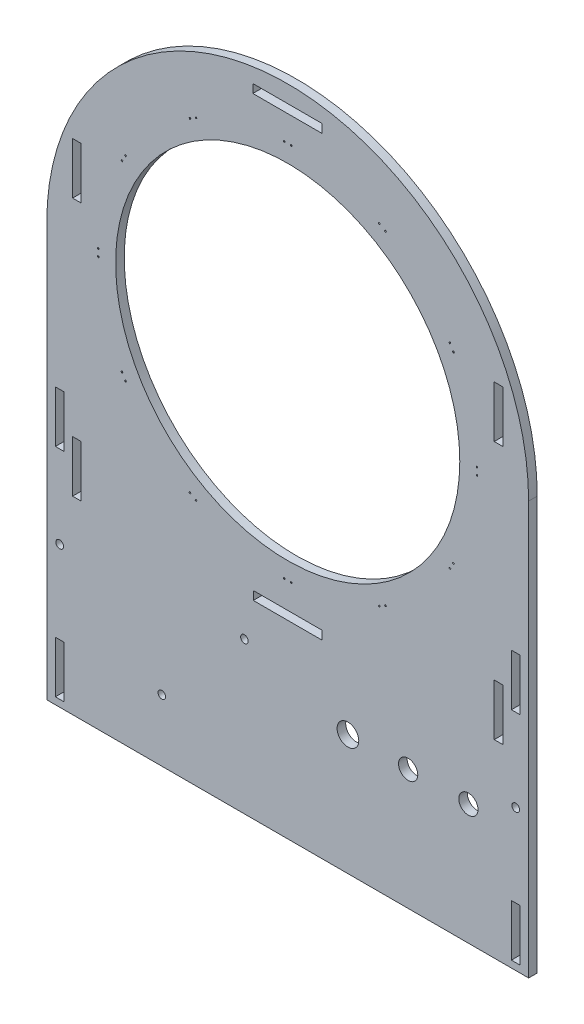
from build123d import *

# Parameters (mm, degrees)
SKETCH1_R           = 63.5
SKETCH1_R_2         = 1.4224
SKETCH1_R_3         = 4
SKETCH1_R_4         = 3.55
SKETCH1_R_5         = 1.397
SKETCH1_W           = 0.5334
SKETCH1_H           = 0.5334
SKETCH1_W_2         = 3.175
SKETCH1_H_2         = 19.05
SKETCH1_W_3         = 25.556343598
SKETCH1_H_3         = 3.175
SKETCH1_W_4         = 25.4
BOSS_EXTRUDE1_DEPTH = 3.175


with BuildPart() as part:
    # Sketch1 → Boss-Extrude1 (new body)
    with BuildSketch(Plane.XY):
        with BuildLine():
            Line((-88.9, 0), (-88.9, -152.4))
            Line((-88.9, -152.4), (88.9, -152.4))
            Line((88.9, -152.4), (88.9, 0))
            ThreePointArc((88.9, 0), (0, 88.9), (-88.9, 0))
        make_face()
        Circle(SKETCH1_R, mode=Mode.SUBTRACT)
        with Locations((-84.1375, -100.33)):
            Circle(SKETCH1_R_2, mode=Mode.SUBTRACT)
        with Locations((84.1375, -100.33)):
            Circle(SKETCH1_R_2, mode=Mode.SUBTRACT)
        with Locations((22.225, -107.95)):
            Circle(SKETCH1_R_3, mode=Mode.SUBTRACT)
        with Locations((44.45, -107.95)):
            Circle(SKETCH1_R_4, mode=Mode.SUBTRACT)
        with Locations((66.675, -107.95)):
            Circle(SKETCH1_R_4, mode=Mode.SUBTRACT)
        with Locations((-15.977581987, -96.52)):
            Circle(SKETCH1_R_5, mode=Mode.SUBTRACT)
        with Locations((-46.457581987, -129.54)):
            Circle(SKETCH1_R_5, mode=Mode.SUBTRACT)
        with Locations((-1.30175, 69.85)):
            Rectangle(SKETCH1_W, SKETCH1_H, mode=Mode.SUBTRACT)
        with Locations((1.30175, 69.85)):
            Rectangle(SKETCH1_W, SKETCH1_H, mode=Mode.SUBTRACT)
        Polygon((33.700032455, 61.50706843), (34.161970406, 61.24036843), (33.895270406, 60.778430479), (33.433332455, 61.045130479), align=None, mode=Mode.SUBTRACT)
        Polygon((35.954729594, 60.20531843), (35.688029594, 59.743380479), (36.149967545, 59.476680479), (36.416667545, 59.93861843), align=None, mode=Mode.SUBTRACT)
        Polygon((59.93861843, 36.416667545), (60.20531843, 35.954729594), (59.743380479, 35.688029594), (59.476680479, 36.149967545), align=None, mode=Mode.SUBTRACT)
        Polygon((61.24036843, 34.161970406), (60.778430479, 33.895270406), (61.045130479, 33.433332455), (61.50706843, 33.700032455), align=None, mode=Mode.SUBTRACT)
        with Locations((69.85, 1.30175)):
            Rectangle(SKETCH1_W, SKETCH1_H, mode=Mode.SUBTRACT)
        with Locations((69.85, -1.30175)):
            Rectangle(SKETCH1_W, SKETCH1_H, mode=Mode.SUBTRACT)
        Polygon((61.50706843, -33.700032455), (61.24036843, -34.161970406), (60.778430479, -33.895270406), (61.045130479, -33.433332455), align=None, mode=Mode.SUBTRACT)
        Polygon((60.20531843, -35.954729594), (59.743380479, -35.688029594), (59.476680479, -36.149967545), (59.93861843, -36.416667545), align=None, mode=Mode.SUBTRACT)
        Polygon((36.416667545, -59.93861843), (35.954729594, -60.20531843), (35.688029594, -59.743380479), (36.149967545, -59.476680479), align=None, mode=Mode.SUBTRACT)
        Polygon((34.161970406, -61.24036843), (33.895270406, -60.778430479), (33.433332455, -61.045130479), (33.700032455, -61.50706843), align=None, mode=Mode.SUBTRACT)
        with Locations((1.30175, -69.85)):
            Rectangle(SKETCH1_W, SKETCH1_H, mode=Mode.SUBTRACT)
        with Locations((-1.30175, -69.85)):
            Rectangle(SKETCH1_W, SKETCH1_H, mode=Mode.SUBTRACT)
        Polygon((-33.700032455, -61.50706843), (-34.161970406, -61.24036843), (-33.895270406, -60.778430479), (-33.433332455, -61.045130479), align=None, mode=Mode.SUBTRACT)
        Polygon((-35.954729594, -60.20531843), (-35.688029594, -59.743380479), (-36.149967545, -59.476680479), (-36.416667545, -59.93861843), align=None, mode=Mode.SUBTRACT)
        Polygon((-59.93861843, -36.416667545), (-60.20531843, -35.954729594), (-59.743380479, -35.688029594), (-59.476680479, -36.149967545), align=None, mode=Mode.SUBTRACT)
        Polygon((-61.24036843, -34.161970406), (-60.778430479, -33.895270406), (-61.045130479, -33.433332455), (-61.50706843, -33.700032455), align=None, mode=Mode.SUBTRACT)
        with Locations((-69.85, -1.30175)):
            Rectangle(SKETCH1_W, SKETCH1_H, mode=Mode.SUBTRACT)
        with Locations((-69.85, 1.30175)):
            Rectangle(SKETCH1_W, SKETCH1_H, mode=Mode.SUBTRACT)
        Polygon((-61.50706843, 33.700032455), (-61.24036843, 34.161970406), (-60.778430479, 33.895270406), (-61.045130479, 33.433332455), align=None, mode=Mode.SUBTRACT)
        Polygon((-60.20531843, 35.954729594), (-59.743380479, 35.688029594), (-59.476680479, 36.149967545), (-59.93861843, 36.416667545), align=None, mode=Mode.SUBTRACT)
        Polygon((-36.416667545, 59.93861843), (-35.954729594, 60.20531843), (-35.688029594, 59.743380479), (-36.149967545, 59.476680479), align=None, mode=Mode.SUBTRACT)
        Polygon((-34.161970406, 61.24036843), (-33.895270406, 60.778430479), (-33.433332455, 61.045130479), (-33.700032455, 61.50706843), align=None, mode=Mode.SUBTRACT)
        with Locations((-77.7875, 22.20976)):
            Rectangle(SKETCH1_W_2, SKETCH1_H_2, mode=Mode.SUBTRACT)
        with Locations((-77.7875, -73.04024)):
            Rectangle(SKETCH1_W_2, SKETCH1_H_2, mode=Mode.SUBTRACT)
        with Locations((-84.1375, -140.335)):
            Rectangle(SKETCH1_W_2, SKETCH1_H_2, mode=Mode.SUBTRACT)
        with Locations((-84.1375, -60.325)):
            Rectangle(SKETCH1_W_2, SKETCH1_H_2, mode=Mode.SUBTRACT)
        with Locations((84.1375, -140.335)):
            Rectangle(SKETCH1_W_2, SKETCH1_H_2, mode=Mode.SUBTRACT)
        with Locations((77.7875, 22.20976)):
            Rectangle(SKETCH1_W_2, SKETCH1_H_2, mode=Mode.SUBTRACT)
        with Locations((84.1375, -60.325)):
            Rectangle(SKETCH1_W_2, SKETCH1_H_2, mode=Mode.SUBTRACT)
        with Locations((77.7875, -73.04024)):
            Rectangle(SKETCH1_W_2, SKETCH1_H_2, mode=Mode.SUBTRACT)
        with Locations((-0.078171799, 80.9625)):
            Rectangle(SKETCH1_W_3, SKETCH1_H_3, mode=Mode.SUBTRACT)
        with Locations((0, -80.9625)):
            Rectangle(SKETCH1_W_4, SKETCH1_H_3, mode=Mode.SUBTRACT)
    extrude(amount=BOSS_EXTRUDE1_DEPTH)


solid = part.part
